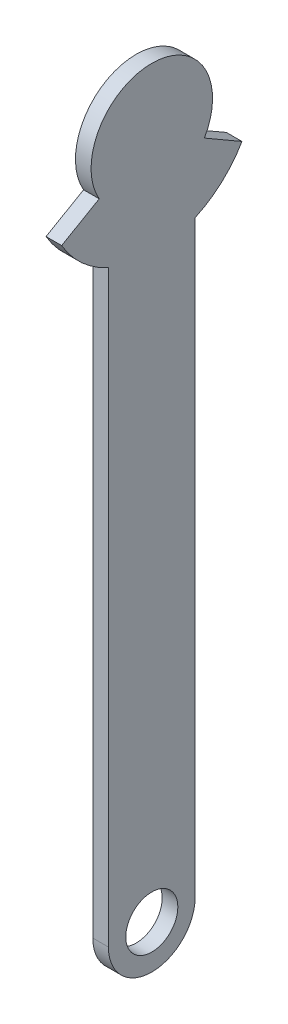
from build123d import *

# Parameters (mm, degrees)
SKETCH1_R           = 15
BOSS_EXTRUDE1_DEPTH = 9


with BuildPart() as part:
    # Sketch1 → Boss-Extrude1 (new body)
    with BuildSketch(Plane(origin=(0, 0, 0), x_dir=(0, 0, -1), z_dir=(1, 0, 0))):
        with BuildLine():
            Line((30.310889132, 179.3), (51.961524227, 166.8))
            ThreePointArc((51.961524227, 166.8), (40.390167668, 152.430704809), (25, 142.256439427))
            Line((25, 142.256439427), (25, -196.8))
            ThreePointArc((25, -196.8), (0, -221.8), (-25, -196.8))
            Line((-25, -196.8), (-25, 142.256439427))
            ThreePointArc((-25, 142.256439427), (-40.390167668, 152.430704809), (-51.961524227, 166.8))
            Line((-51.961524227, 166.8), (-30.310889132, 179.3))
            ThreePointArc((-30.310889132, 179.3), (0, 231.8), (30.310889132, 179.3))
        make_face()
        with Locations((0, -196.8)):
            Circle(SKETCH1_R, mode=Mode.SUBTRACT)
    extrude(amount=BOSS_EXTRUDE1_DEPTH)


solid = part.part
